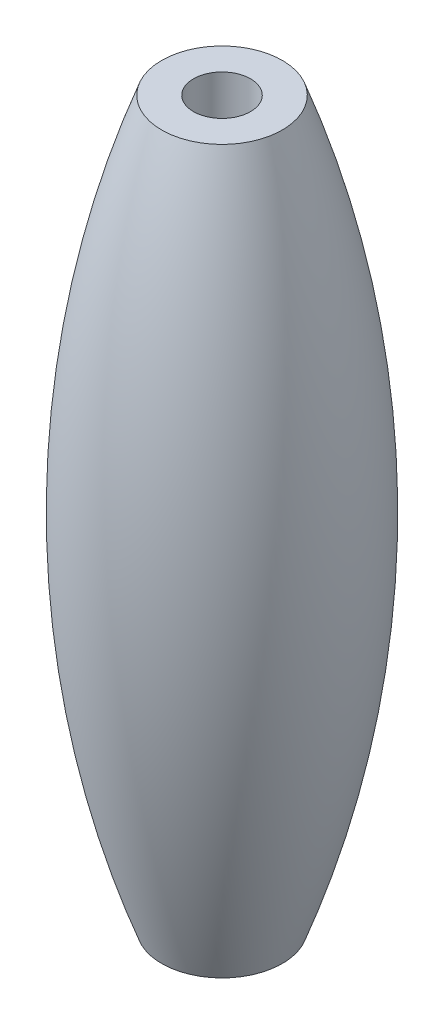
from build123d import *

# Parameters (mm, degrees)
F_3_0MM_DOWEL_HOLE1_D = 3


with BuildPart() as part:
    # Sketch1 → Revolve1 (revolve)
    with BuildSketch(Plane.XY):
        with BuildLine():
            Line((0, 17.871301358), (3.175, 17.871301358))
            ThreePointArc((3.175, 17.871301358), (6.540114752, -1.128698642), (3.175, -20.128698642))
            Line((3.175, -20.128698642), (0, -20.128698642))
            Line((0, -20.128698642), (0, 17.871301358))
        make_face()
    revolve(axis=Axis((0, 17.871301358, 0), (0, -1, 0)))

    # Ø3.0mm Dowel Hole1 (through all)
    with Locations(Plane(origin=(0, 17.871301358, 0), x_dir=(1, 0, 0), z_dir=(0, 1, 0))):
        with Locations((0, 0)):
            Hole(F_3_0MM_DOWEL_HOLE1_D / 2)


solid = part.part
